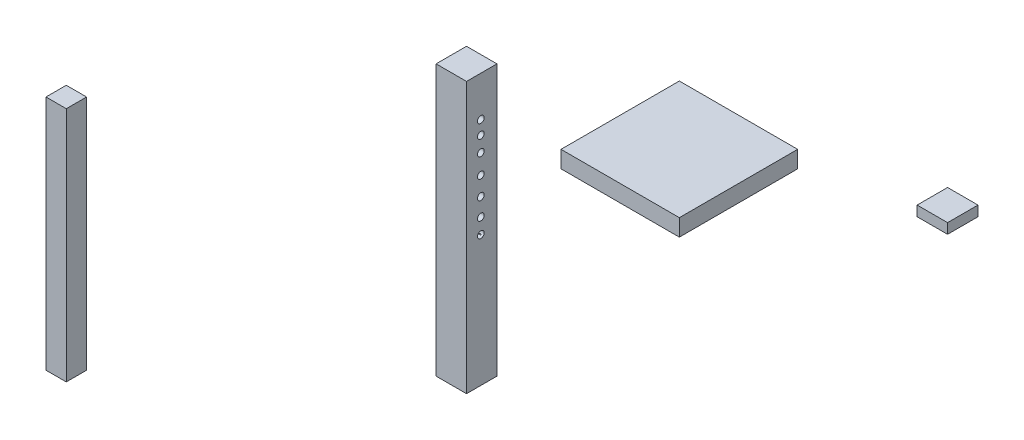
from build123d import *

# Parameters (mm, degrees)
SKETCH1_W           = 90
SKETCH1_H           = 90
BOSS_EXTRUDE2_DEPTH = 30
SKETCH2_W           = 350
SKETCH2_H           = 350
BOSS_EXTRUDE3_DEPTH = 50
SKETCH3_W           = 90
SKETCH3_H           = 90
BOSS_EXTRUDE4_DEPTH = 800
SKETCH5_W           = 60
SKETCH5_H           = 60
BOSS_EXTRUDE5_DEPTH = 700
SKETCH4_R           = 10
SKETCH4_R_2         = 1
CUT_EXTRUDE2_DEPTH  = 583.058021663


with BuildPart() as part:
    # Sketch1 → Boss-Extrude2 (new body)
    with BuildSketch(Plane(origin=(0, 0, 0), x_dir=(1, 0, 0), z_dir=(0, 1, 0))):
        with Locations((12.132228886, 60.103304997)):
            Rectangle(SKETCH1_W, SKETCH1_H)
    extrude(amount=-BOSS_EXTRUDE2_DEPTH)


with BuildPart() as body_2:
    # Sketch2 → Boss-Extrude3 (new body)
    with BuildSketch(Plane(origin=(0, 0, 0), x_dir=(1, 0, 0), z_dir=(0, 1, 0))):
        with Locations((-527.284369239, -193.819852957)):
            Rectangle(SKETCH2_W, SKETCH2_H)
    extrude(amount=-BOSS_EXTRUDE3_DEPTH)


with BuildPart() as body_3:
    # Sketch3 → Boss-Extrude4 (new body)
    with BuildSketch(Plane(origin=(0, 0, 0), x_dir=(1, 0, 0), z_dir=(0, 1, 0))):
        with Locations((-1060.997560956, -289.608602032)):
            Rectangle(SKETCH3_W, SKETCH3_H)
    extrude(amount=-BOSS_EXTRUDE4_DEPTH)

    # Sketch4 → Cut-Extrude2 (cut, through all)
    with BuildSketch(Plane(origin=(-1015.997560956, 0, 0), x_dir=(0, 0, -1), z_dir=(1, 0, 0))):
        with Locations((-292.26565685, -118.793047126)):
            Circle(SKETCH4_R)
        with Locations((-292.26565685, -158.765450593)):
            Circle(SKETCH4_R)
        with Locations((-292.26565685, -203.734404493)):
            Circle(SKETCH4_R)
        with Locations((-292.26565685, -261.194734476)):
            Circle(SKETCH4_R)
        with Locations((-292.26565685, -316.156789243)):
            Circle(SKETCH4_R)
        with Locations((-292.26565685, -368.620568793)):
            Circle(SKETCH4_R)
        with Locations((-292.26565685, -413.589522693)):
            Circle(SKETCH4_R)
        with Locations((-292.26565685, -413.589522693)):
            Circle(SKETCH4_R_2, mode=Mode.SUBTRACT)
    extrude(amount=-CUT_EXTRUDE2_DEPTH, mode=Mode.SUBTRACT)


with BuildPart() as body_4:
    # Sketch5 → Boss-Extrude5 (new body)
    with BuildSketch(Plane(origin=(0, 0, 0), x_dir=(1, 0, 0), z_dir=(0, 1, 0))):
        with Locations((-1568.055582619, -966.375876907)):
            Rectangle(SKETCH5_W, SKETCH5_H)
    extrude(amount=-BOSS_EXTRUDE5_DEPTH)


solid = Compound([part.part, body_2.part, body_3.part, body_4.part])
